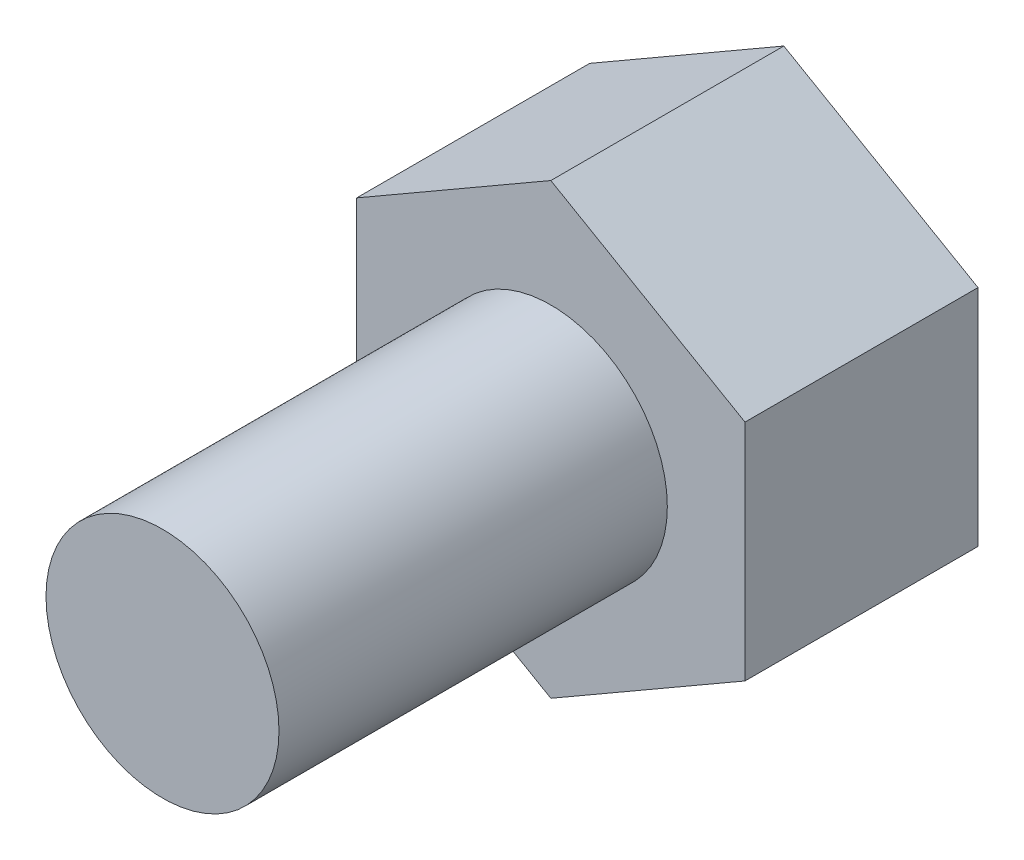
from build123d import *

# Parameters (mm, degrees)
SKETCH1_R           = 1.5
BOSS_EXTRUDE1_DEPTH = 5
BOSS_EXTRUDE2_DEPTH = 3


with BuildPart() as part:
    # Sketch1 → Boss-Extrude1 (new body)
    with BuildSketch(Plane.XY):
        with Locations((-63.49476159, 14.978708134)):
            Circle(SKETCH1_R)
    extrude(amount=BOSS_EXTRUDE1_DEPTH)

    # Sketch2 → Boss-Extrude2 (add)
    with BuildSketch(Plane(origin=(0, 0, 0), x_dir=(-1, 0, 0), z_dir=(0, 0, -1))):
        Polygon((63.49476159, 12.091956788), (65.99476159, 13.535332461), (65.99476159, 16.422083807), (63.49476159, 17.86545948), (60.99476159, 16.422083807), (60.99476159, 13.535332461), align=None)
    extrude(amount=BOSS_EXTRUDE2_DEPTH)


solid = part.part
